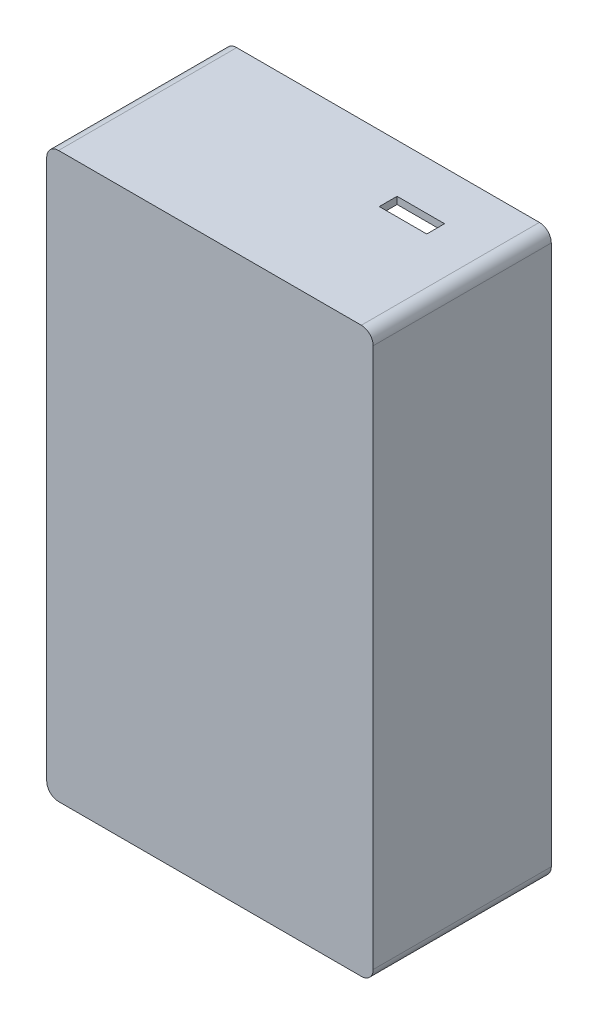
from build123d import *

# Parameters (mm, degrees)
SKETCH1_W           = 55
SKETCH1_H           = 95
BOSS_EXTRUDE1_DEPTH = 30
SKETCH2_W           = 52.6
SKETCH2_H           = 92.6
CUT_EXTRUDE1_DEPTH  = 28.8
SKETCH3_R           = 3.5
BOSS_EXTRUDE2_DEPTH = 16
SKETCH6_R           = 1.6
BOSS_EXTRUDE3_DEPTH = 1.5
FILLET3_R           = 2
SKETCH8_W           = 44.2
SKETCH8_H           = 32.4
BOSS_EXTRUDE4_DEPTH = 10
SKETCH9_W           = 43
SKETCH9_H           = 30
CUT_EXTRUDE3_DEPTH  = 10
CUT_EXTRUDE4_REACH  = 97
SKETCH11_W          = 8
SKETCH11_H          = 3
SKETCH7_R           = 1.2
CUT_EXTRUDE5_DEPTH  = 16


with BuildPart() as part:
    # Sketch1 → Boss-Extrude1 (new body)
    with BuildSketch(Plane.XY):
        with Locations((27.5, -47.5)):
            Rectangle(SKETCH1_W, SKETCH1_H)
    extrude(amount=BOSS_EXTRUDE1_DEPTH)

    # Sketch2 → Cut-Extrude1 (cut)
    with BuildSketch(Plane(origin=(0, 0, 0), x_dir=(-1, 0, 0), z_dir=(0, 0, -1))):
        with Locations((-27.5, -47.5)):
            Rectangle(SKETCH2_W, SKETCH2_H)
    extrude(amount=-CUT_EXTRUDE1_DEPTH, mode=Mode.SUBTRACT)

    # Sketch3 → Boss-Extrude2 (add)
    with BuildSketch(Plane(origin=(0, 0, 28.8), x_dir=(-1, 0, 0), z_dir=(0, 0, -1))):
        with Locations((-4.2, -4.2)):
            Circle(SKETCH3_R)
        with Locations((-48.2, -4.2)):
            Circle(SKETCH3_R)
        with Locations((-48.2, -88.2)):
            Circle(SKETCH3_R)
        with Locations((-4.2, -88.2)):
            Circle(SKETCH3_R)
    extrude(amount=BOSS_EXTRUDE2_DEPTH)

    # Sketch6 → Boss-Extrude3 (add)
    with BuildSketch(Plane(origin=(0, 0, 12.8), x_dir=(-1, 0, 0), z_dir=(0, 0, -1))):
        with Locations((-4.2, -4.2)):
            Circle(SKETCH6_R)
        with Locations((-48.2, -4.2)):
            Circle(SKETCH6_R)
        with Locations((-48.2, -88.2)):
            Circle(SKETCH6_R)
        with Locations((-4.2, -88.2)):
            Circle(SKETCH6_R)
    extrude(amount=BOSS_EXTRUDE3_DEPTH)

    # Fillet3
    fillet3_edges = [part.edges().sort_by_distance(p)[0] for p in [
        (0, 0, 15),
        (55, 0, 15),
        (55, -95, 15),
        (0, -95, 15),
    ]]
    fillet(fillet3_edges, radius=FILLET3_R)

    # Sketch8 → Boss-Extrude4 (add)
    with BuildSketch(Plane(origin=(0, 0, 28.8), x_dir=(-1, 0, 0), z_dir=(0, 0, -1))):
        with Locations((-31.7, -37.4)):
            Rectangle(SKETCH8_W, SKETCH8_H)
    extrude(amount=BOSS_EXTRUDE4_DEPTH)

    # Sketch9 → Cut-Extrude3 (cut)
    with BuildSketch(Plane(origin=(0, 0, 18.8), x_dir=(-1, 0, 0), z_dir=(0, 0, -1))):
        with Locations((-32.3, -37.4)):
            Rectangle(SKETCH9_W, SKETCH9_H)
    extrude(amount=-CUT_EXTRUDE3_DEPTH, mode=Mode.SUBTRACT)

    # Sketch11 → Cut-Extrude4 (cut, up to next)
    with BuildSketch(Plane(origin=(0, 0, 0), x_dir=(1, 0, 0), z_dir=(0, 1, 0)), mode=Mode.PRIVATE) as cut_extrude4_sk1:
        with Locations((41.2, -9.68)):
            Rectangle(SKETCH11_W, SKETCH11_H)
    cut_extrude4_tool1 = extrude(cut_extrude4_sk1.sketch, amount=-CUT_EXTRUDE4_REACH, mode=Mode.PRIVATE) & part.part
    add(cut_extrude4_tool1.solids().sort_by_distance((41.2, 0, 9.68))[0], mode=Mode.SUBTRACT)

    # Sketch7 → Cut-Extrude5 (cut)
    with BuildSketch(Plane(origin=(0, 0, 11.3), x_dir=(-1, 0, 0), z_dir=(0, 0, -1))):
        with Locations((-4.2, -4.2)):
            Circle(SKETCH7_R)
        with Locations((-48.2, -4.2)):
            Circle(SKETCH7_R)
        with Locations((-48.2, -88.2)):
            Circle(SKETCH7_R)
        with Locations((-4.2, -88.2)):
            Circle(SKETCH7_R)
    extrude(amount=-CUT_EXTRUDE5_DEPTH, mode=Mode.SUBTRACT)


solid = part.part
